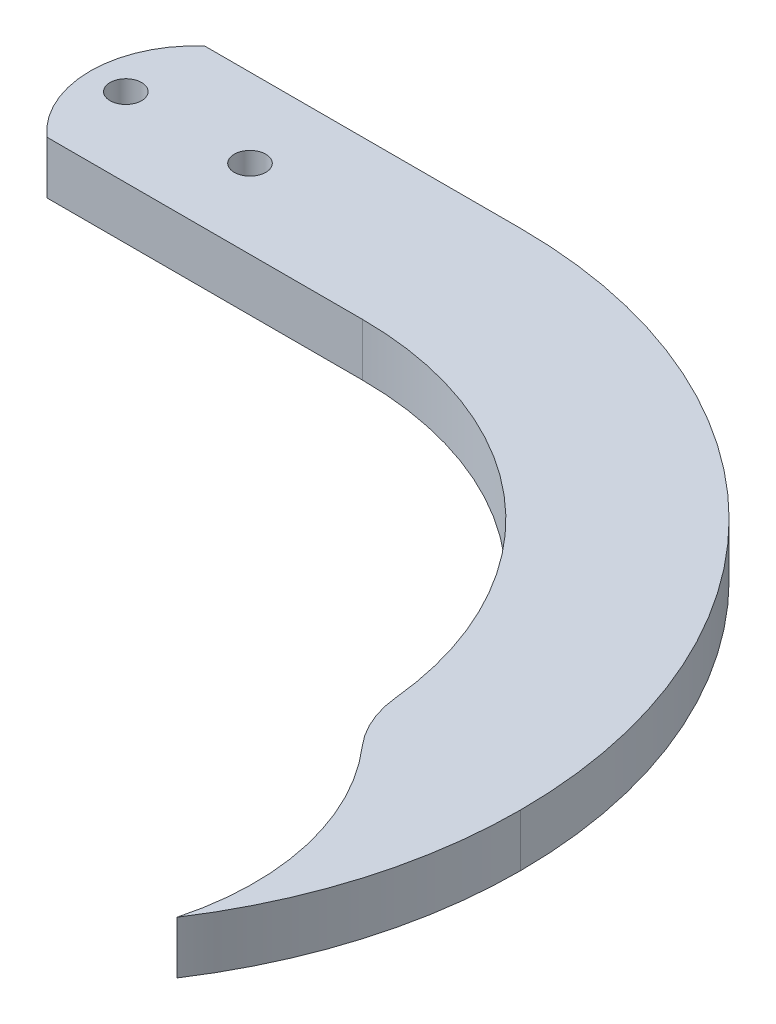
from build123d import *

# Parameters (mm, degrees)
SKETCH1_R           = 1.5
BOSS_EXTRUDE1_DEPTH = 5
CUT_EXTRUDE1_DEPTH  = 10
BOSS_EXTRUDE2_DEPTH = 5
CUT_EXTRUDE2_DEPTH  = 10
FILLET1_R           = 10


with BuildPart() as part:
    # Sketch1 → Boss-Extrude1 (new body)
    with BuildSketch(Plane(origin=(0, 0, 0), x_dir=(1, 0, 0), z_dir=(0, 1, 0))):
        with BuildLine():
            ThreePointArc((30, 7.5), (22.5, 0), (30, -7.5))
            Line((30, -7.5), (0, -7.5))
            ThreePointArc((0, -7.5), (-7.5, 0), (0, 7.5))
            Line((0, 7.5), (30, 7.5))
        make_face()
        with Locations((11.8, 0)):
            Circle(SKETCH1_R, mode=Mode.SUBTRACT)
        Circle(SKETCH1_R, mode=Mode.SUBTRACT)
        with BuildLine():
            ThreePointArc((30, -7.5), (37.5, 0), (30, 7.5))
            ThreePointArc((30, 7.5), (22.5, 0), (30, -7.5))
        make_face()
        with BuildLine():
            ThreePointArc((62.875, -40.375), (53.246135432, -17.128864568), (30, -7.5))
            ThreePointArc((30, -7.5), (37.5, 0), (30, 7.5))
            ThreePointArc((30, 7.5), (63.852737149, -6.522262851), (77.875, -40.375))
            ThreePointArc((77.875, -40.375), (70.375, -47.875), (62.875, -40.375))
        make_face()
    extrude(amount=BOSS_EXTRUDE1_DEPTH)

    # Sketch2 → Cut-Extrude1 (cut)
    with BuildSketch(Plane(origin=(0, 5, 0), x_dir=(1, 0, 0), z_dir=(0, 1, 0))):
        with BuildLine():
            ThreePointArc((0, 7.5), (-7.5, 0), (0, -7.5))
            ThreePointArc((0, -7.5), (-3.385621722, 0), (0, 7.5))
        make_face()
    extrude(amount=-CUT_EXTRUDE1_DEPTH, mode=Mode.SUBTRACT)

    # Sketch3 → Boss-Extrude2 (add)
    with BuildSketch(Plane(origin=(0, 5, 0), x_dir=(1, 0, 0), z_dir=(0, 1, 0))):
        with BuildLine():
            ThreePointArc((77.875, -40.375), (74.960699845, -46.309758372), (68.482638152, -47.632338812))
            ThreePointArc((68.482638152, -47.632338812), (71.093194767, -56.399789932), (70.375, -65.519406222))
            ThreePointArc((70.375, -65.519406222), (75.960053745, -53.494557579), (77.875, -40.375))
        make_face()
    extrude(amount=-BOSS_EXTRUDE2_DEPTH)

    # Sketch4 → Cut-Extrude2 (cut)
    with BuildSketch(Plane(origin=(0, 5, 0), x_dir=(1, 0, 0), z_dir=(0, 1, 0))):
        with BuildLine():
            ThreePointArc((62.875, -40.375), (64.440241628, -44.960699845), (68.482638152, -47.632338812))
            ThreePointArc((68.482638152, -47.632338812), (66.014466289, -43.744319779), (62.875, -40.375))
        make_face()
    extrude(amount=-CUT_EXTRUDE2_DEPTH, mode=Mode.SUBTRACT)

    # Fillet1
    fillet1_edges = [part.edges().sort_by_distance(p)[0] for p in [
        (62.875, 2.5, 40.375),
    ]]
    fillet(fillet1_edges, radius=FILLET1_R)


solid = part.part
